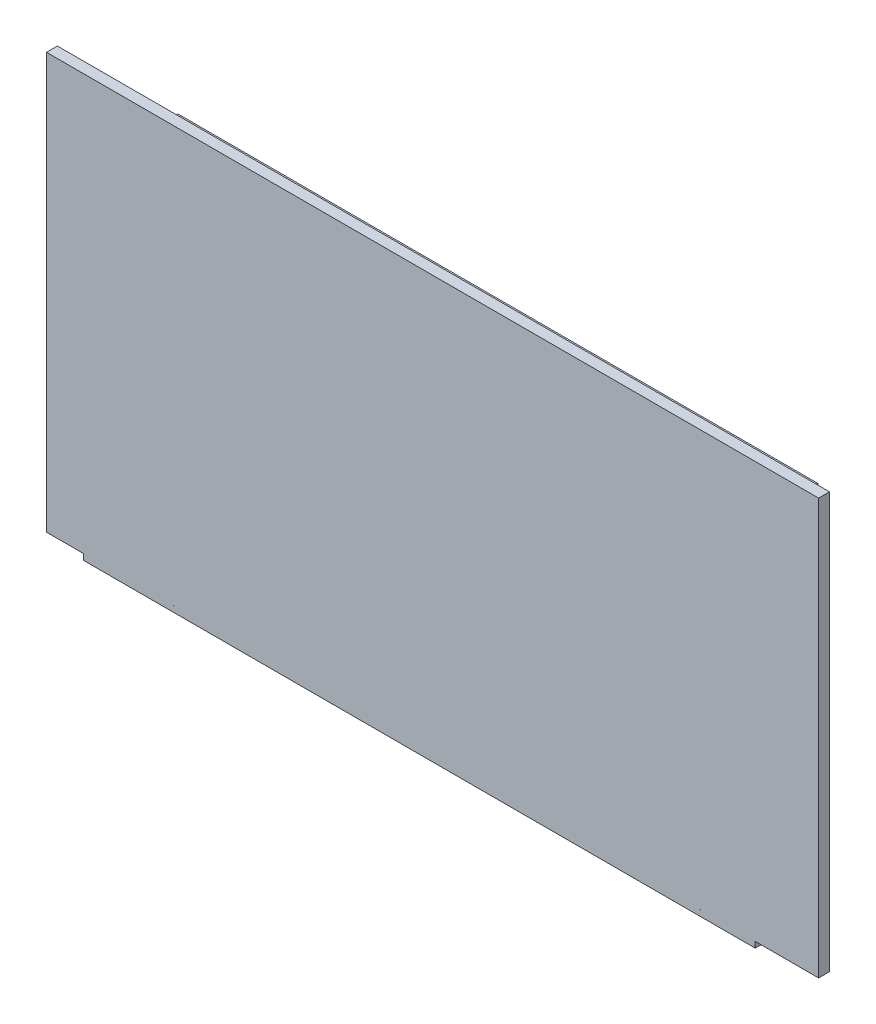
from build123d import *

# Parameters (mm, degrees)
ESBO_O1_W                 = 105
ESBO_O1_H                 = 60
RESSALTO_EXTRUS_O1_DEPTH  = 1.7
RESSALTO_EXTRUS_O6_START  = 11.6
ESBO_O3_W                 = 100
ESBO_O3_H                 = 53
RESSALTO_EXTRUS_O6_DEPTH  = 1.5
ESBO_O4_W                 = 62.184169383
ESBO_O4_H                 = 2.54
ESBO_O4_W_2               = 5.08
ESBO_O4_H_2               = 42.957805244
ESBO_O4_W_3               = 56.07185462
RESSALTO_EXTRUS_O8_DEPTH  = 11.6
ESBO_O7_W                 = 25.746964405
ESBO_O7_H                 = 12
RESSALTO_EXTRUS_O10_DEPTH = 10
ESBO_O8_R                 = 1.5
ESBO_O8_W                 = 105
ESBO_O8_H                 = 7.9
CORTE_EXTRUS_O1_DEPTH     = 15.8
ESBO_O9_W                 = 120.671020404
ESBO_O9_H                 = 64.953228707
RESSALTO_EXTRUS_O11_DEPTH = 1.7


with BuildPart() as part:
    # Esboço1 → Ressalto-extrusão1 (new body)
    with BuildSketch(Plane.XY):
        Rectangle(ESBO_O1_W, ESBO_O1_H)
    extrude(amount=RESSALTO_EXTRUS_O1_DEPTH)



with BuildPart() as body_2:
    # Esboço3 → Ressalto-extrusão6 (new body)
    with BuildSketch(Plane(origin=(0, 0, 0), x_dir=(-1, 0, 0), z_dir=(0, 0, -1)).offset(RESSALTO_EXTRUS_O6_START)):
        with Locations((2.5, 4.4)):
            Rectangle(ESBO_O3_W, ESBO_O3_H)
    extrude(amount=RESSALTO_EXTRUS_O6_DEPTH)


with BuildPart() as part_1:
    add(part.part)

    add(body_2.part)  # Ressalto-extrusão8 merges body 2
    # Esboço4 → Ressalto-extrusão8 (add)
    with BuildSketch(Plane.XY.offset(-11.6)):
        with Locations((7.150543675, 26.719832293)):
            Rectangle(ESBO_O4_W, ESBO_O4_H)
        with Locations((45.784919315, 5.42627648)):
            Rectangle(ESBO_O4_W_2, ESBO_O4_H_2)
        with Locations((10.206701056, -18.689881399)):
            Rectangle(ESBO_O4_W_3, ESBO_O4_H)
    extrude(amount=RESSALTO_EXTRUS_O8_DEPTH)

    # Esboço7 → Ressalto-extrusão10 (add)
    with BuildSketch(Plane.XY.offset(-11.6)):
        with Locations((-47.626517798, 17.9)):
            Rectangle(ESBO_O7_W, ESBO_O7_H)
    extrude(amount=RESSALTO_EXTRUS_O10_DEPTH)

    # Esboço8 → Corte-extrusão1 (cut, through all)
    with BuildSketch(Plane(origin=(0, 0, -13.1), x_dir=(-1, 0, 0), z_dir=(0, 0, -1))):
        with Locations((37.26, 28.47)):
            Circle(ESBO_O8_R)
        with Locations((38.5, -19.7)):
            Circle(ESBO_O8_R)
        with Locations((-43.8, -19.7)):
            Circle(ESBO_O8_R)
        with Locations((0, -26.05)):
            Rectangle(ESBO_O8_W, ESBO_O8_H)
    extrude(amount=-CORTE_EXTRUS_O1_DEPTH, mode=Mode.SUBTRACT)

    # Esboço9 → Ressalto-extrusão11 (add)
    with BuildSketch(Plane.XY.offset(1.7)):
        with Locations((2.076306878, 11.29693703)):
            Rectangle(ESBO_O9_W, ESBO_O9_H)
    extrude(amount=-RESSALTO_EXTRUS_O11_DEPTH)


solid = part_1.part
